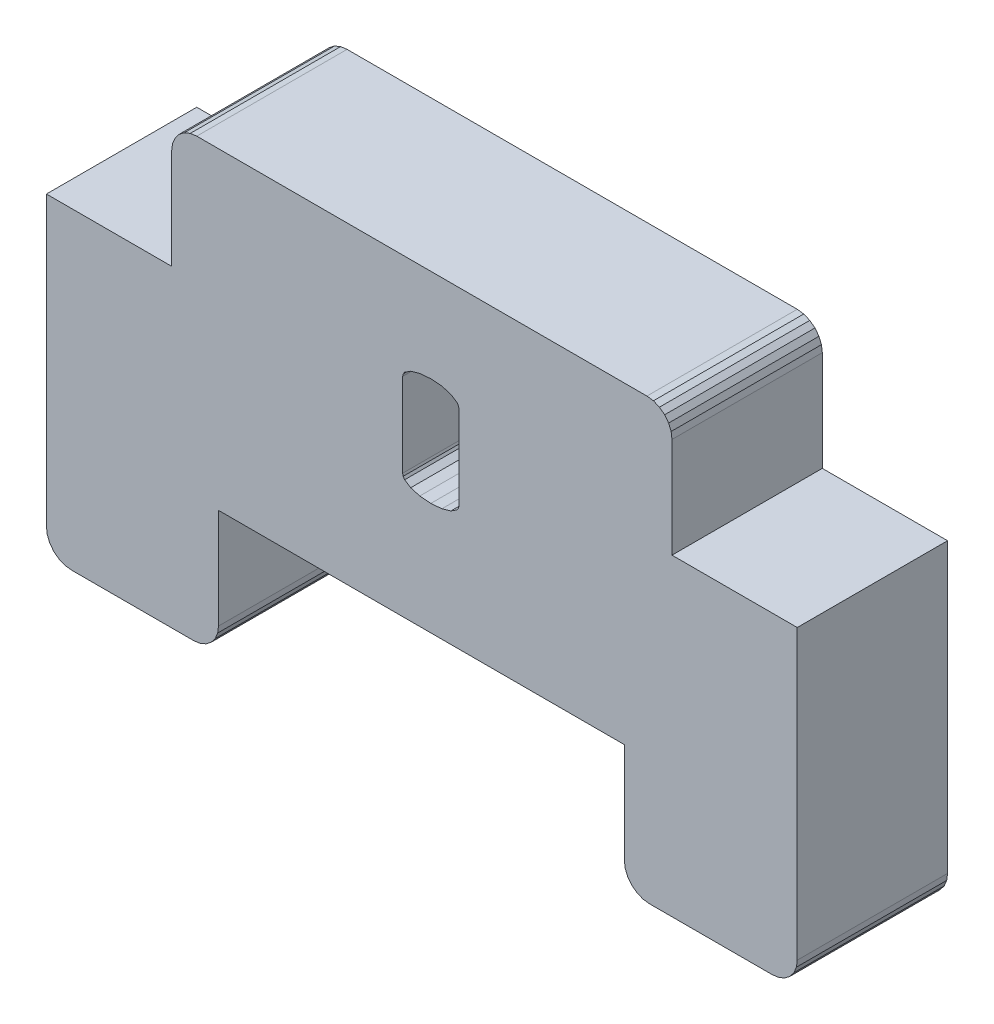
from build123d import *

# Parameters (mm, degrees)
BOSS_EXTRUDE1_DEPTH = 6


with BuildPart() as part:
    # Sketch1 → Boss-Extrude1 (new body)
    with BuildSketch(Plane.XY):
        Polygon((-477.021328122, -244.872375969), (-477.280147167, -244.906450143), (-482.180147167, -244.906450143), (-482.438966212, -244.872375969), (-482.680147167, -244.772475547), (-482.887253948, -244.613556924), (-483.046172571, -244.406450143), (-483.146072993, -244.165269188), (-483.180147167, -243.906450143), (-483.180147167, -239.906450143), (-499.380142171, -239.906450143), (-499.380142171, -243.906450143), (-499.414216344, -244.165269188), (-499.514116767, -244.406450143), (-499.67303539, -244.613556924), (-499.880142171, -244.772475547), (-500.121323126, -244.872375969), (-500.380142171, -244.906450143), (-505.248606329, -244.906450143), (-505.507425374, -244.872375969), (-505.748606329, -244.772475547), (-505.95571311, -244.613556924), (-506.114631732, -244.406450143), (-506.214532155, -244.165269188), (-506.248606329, -243.906450143), (-506.248606329, -232.406450143), (-501.248606329, -232.406450143), (-501.248606329, -228.406450143), (-501.214532155, -228.147631098), (-501.114631732, -227.906450143), (-500.95571311, -227.699343362), (-500.748606329, -227.540424739), (-500.507425374, -227.440524317), (-500.248606329, -227.406450143), (-482.280147167, -227.406450143), (-482.021328122, -227.440524317), (-481.780147167, -227.540424739), (-481.573040386, -227.699343362), (-481.414121763, -227.906450143), (-481.314221341, -228.147631098), (-481.280147167, -228.406450143), (-481.280147167, -232.406450143), (-476.280147167, -232.406450143), (-476.280147167, -243.906450143), (-476.314221341, -244.165269188), (-476.414121763, -244.406450143), (-476.573040386, -244.613556924), (-476.780147167, -244.772475547), align=None)
        Polygon((-492.029860545, -234.949153278), (-492.009763604, -235.045362548), (-491.949472778, -235.134152325), (-491.708309478, -235.2894734), (-491.346945625, -235.394834966), (-490.905956201, -235.429955488), (-490.464966776, -235.394834966), (-490.103602923, -235.2894734), (-489.862439623, -235.134152325), (-489.802148798, -235.045362548), (-489.782051856, -234.949153278), (-489.782051856, -231.602449772), (-489.802148798, -231.506259854), (-489.862439623, -231.417480498), (-490.103602923, -231.262153468), (-490.464966776, -231.156774038), (-490.905956201, -231.121647561), (-491.346945625, -231.156774038), (-491.708309478, -231.262153468), (-491.949472778, -231.417480498), (-492.009763604, -231.506259854), (-492.029860545, -231.602449772), align=None, mode=Mode.SUBTRACT)
    extrude(amount=BOSS_EXTRUDE1_DEPTH)


solid = part.part
